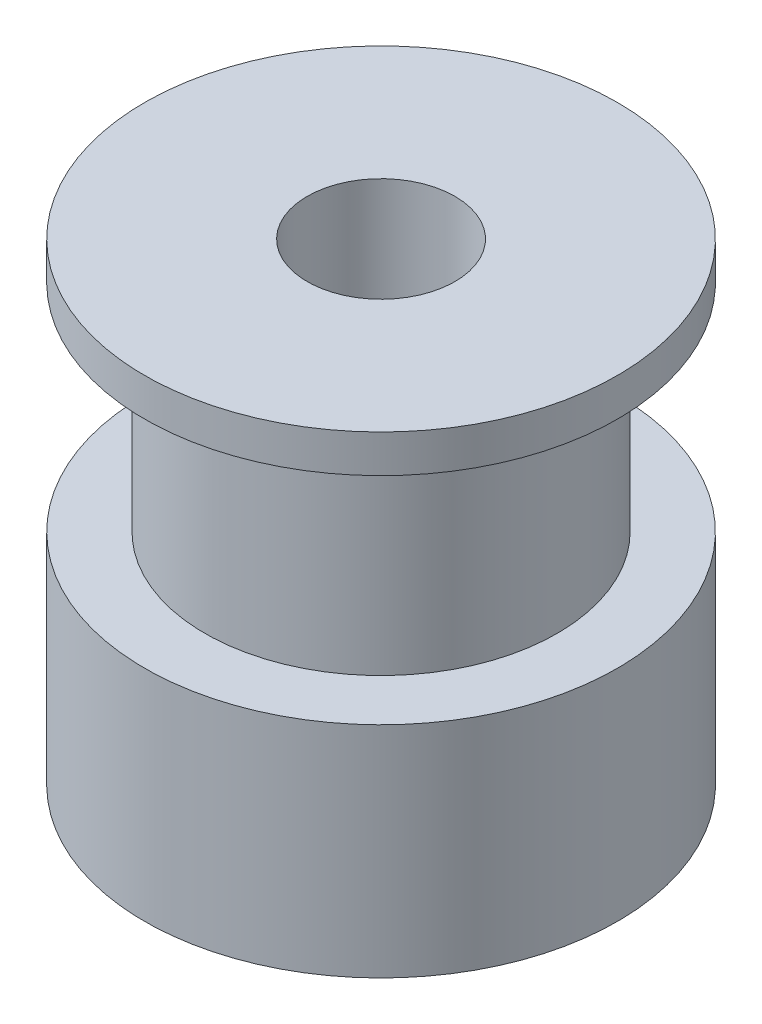
from build123d import *


with BuildPart() as part:
    # Sketch1 → Revolve1 (revolve)
    with BuildSketch(Plane.XY):
        Polygon((2.5, 0), (2.5, 16), (8, 16), (8, 14.72), (5.96, 14.72), (5.96, 7.42), (8, 7.42), (8, 0), align=None)
    revolve(axis=Axis((0, 0, 0), (0, 1, 0)))


solid = part.part
